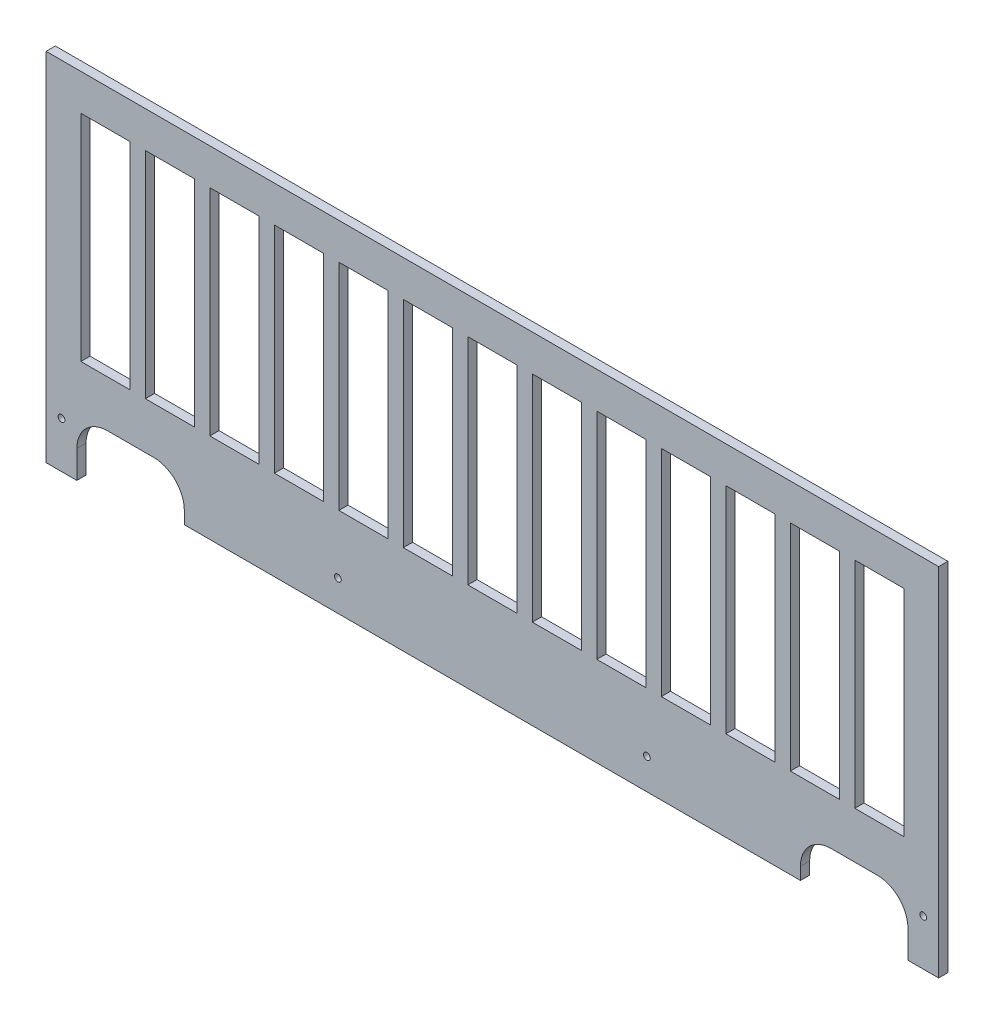
from build123d import *

# Parameters (mm, degrees)
ESQUISSE5_R      = 1.1
ESQUISSE5_W      = 16
ESQUISSE5_H      = 70
ESQUISSE5_W_2    = 15.999999999
EXTRUSION1_DEPTH = 3


with BuildPart() as part:
    # Esquisse5 → Extrusion1 (new body)
    with BuildSketch(Plane.XY):
        with BuildLine():
            Line((-3.928476502, 116), (286.670329677, 116))
            Line((286.670329677, 116), (286.670329677, 0))
            Line((286.670329677, 0), (276.670329677, 0))
            Line((276.670329677, 0), (276.670329677, 8.999999996))
            ThreePointArc((276.670329677, 8.999999996), (273.741442764, 16.071150589), (266.670329677, 19.000128051))
            Line((266.670329677, 19.000128051), (251.670329678, 19.000128051))
            ThreePointArc((251.670329678, 19.000128051), (244.599261866, 16.071195863), (241.670329677, 9.000128051))
            Line((241.670329677, 9.000128051), (241.670329677, 5.000128051))
            Line((241.670329677, 5.000128051), (41.070037623, 5.000128051))
            Line((41.070037623, 5.000128051), (41.070037623, 9.000128051))
            ThreePointArc((41.070037623, 9.000128051), (38.141105434, 16.071195863), (31.070037623, 19.000128051))
            Line((31.070037623, 19.000128051), (16.070037622, 19.000128051))
            ThreePointArc((16.070037622, 19.000128051), (8.998969811, 16.071195863), (6.070037623, 9.000128051))
            Line((6.070037623, 9.000128051), (6.070037623, 0))
            Line((6.070037623, 0), (-3.928476502, 0))
            Line((-3.928476502, 0), (-3.928476502, 116))
        make_face()
        with Locations((191.670329678, 14.999972575)):
            Circle(ESQUISSE5_R, mode=Mode.SUBTRACT)
        with Locations((1.071523498, 14.999972575)):
            Circle(ESQUISSE5_R, mode=Mode.SUBTRACT)
        with Locations((91.071523498, 14.999972575)):
            Circle(ESQUISSE5_R, mode=Mode.SUBTRACT)
        with Locations((281.670329677, 14.999972575)):
            Circle(ESQUISSE5_R, mode=Mode.SUBTRACT)
        Polygon((28.373009183, 104.2), (44.373009183, 104.2), (44.373009183, 34.2), (28.373009183, 34.2), align=None, mode=Mode.SUBTRACT)
        with Locations((15.373009183, 69.2)):
            Rectangle(ESQUISSE5_W, ESQUISSE5_H, mode=Mode.SUBTRACT)
        with Locations((57.373009183, 69.2)):
            Rectangle(ESQUISSE5_W, ESQUISSE5_H, mode=Mode.SUBTRACT)
        with Locations((78.373009183, 69.2)):
            Rectangle(ESQUISSE5_W, ESQUISSE5_H, mode=Mode.SUBTRACT)
        with Locations((99.373009183, 69.2)):
            Rectangle(ESQUISSE5_W, ESQUISSE5_H, mode=Mode.SUBTRACT)
        with Locations((120.373009183, 69.2)):
            Rectangle(ESQUISSE5_W, ESQUISSE5_H, mode=Mode.SUBTRACT)
        with Locations((141.373009183, 69.2)):
            Rectangle(ESQUISSE5_W, ESQUISSE5_H, mode=Mode.SUBTRACT)
        with Locations((162.373009183, 69.2)):
            Rectangle(ESQUISSE5_W_2, ESQUISSE5_H, mode=Mode.SUBTRACT)
        with Locations((183.373009182, 69.2)):
            Rectangle(ESQUISSE5_W, ESQUISSE5_H, mode=Mode.SUBTRACT)
        with Locations((204.373009182, 69.2)):
            Rectangle(ESQUISSE5_W, ESQUISSE5_H, mode=Mode.SUBTRACT)
        with Locations((225.373009182, 69.2)):
            Rectangle(ESQUISSE5_W, ESQUISSE5_H, mode=Mode.SUBTRACT)
        with Locations((246.373009182, 69.2)):
            Rectangle(ESQUISSE5_W, ESQUISSE5_H, mode=Mode.SUBTRACT)
        with Locations((267.373009182, 69.2)):
            Rectangle(ESQUISSE5_W, ESQUISSE5_H, mode=Mode.SUBTRACT)
    extrude(amount=EXTRUSION1_DEPTH)


solid = part.part
